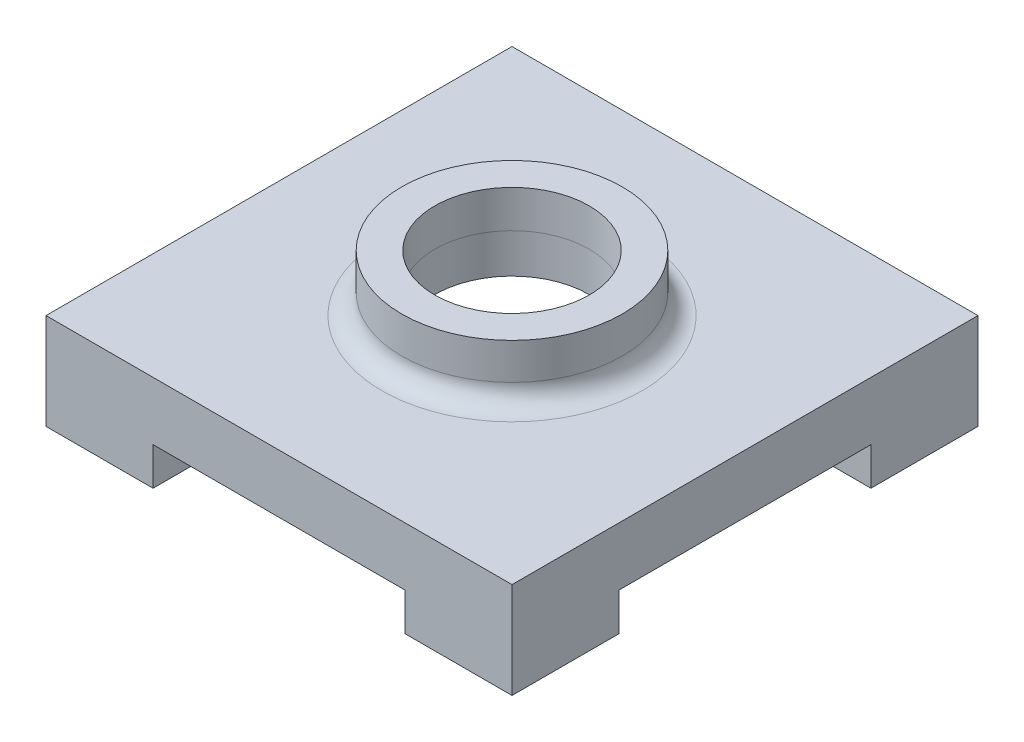
from build123d import *

# Parameters (mm, degrees)
SKETCH1_W            = 18.25
SKETCH1_H            = 40
OUTLINE_DEPTH        = 40
OUTLINE_DEPTH_BACK   = 40
SKETCH2_W            = 40
SKETCH2_H            = 80
EXTRUSION15_DEPTH    = 6
CAMERA_MOUNT_D       = 24.5364
SKETCH5_R            = 17.5
SKETCH5_R_2          = 12.268
EXTRUSION19_DEPTH    = 5.9562
SKETCH10_W           = 80
SKETCH10_H           = 80
SKETCH10_R           = 17.5
CUT_EXTRUDE1_DEPTH   = 3
SKETCH6_W            = 80
SKETCH6_H            = 40
EXTRUSION21_DEPTH    = 6
SKETCH7_W            = 50
SKETCH7_H            = 50
EXTRUSION22_DEPTH    = 9
FILLET4_R            = 3.175
HOLE7_D              = 3.3
HOLE7_DEPTH          = 12
HOLE7_TIP            = 0.991420021
SKETCH11_OUTSIDE_W   = 105.14
SKETCH11_OUTSIDE_H   = 105.14
SKETCH11_OUTSIDE_W_2 = 74
SKETCH11_OUTSIDE_H_2 = 74
CUT_EXTRUDE2_DEPTH   = 16.25
CUT_EXTRUDE3_DEPTH   = 3


with BuildPart() as part:
    # Sketch1 → Outline (new body, two sides)
    with BuildSketch(Plane.YZ) as outline_sk:
        Polygon((18.25, 40), (5.33, 40), (0, 40), (0, 0), (18.25, 0), align=None)
        with Locations((9.125, -20)):
            Rectangle(SKETCH1_W, SKETCH1_H)
    extrude(amount=OUTLINE_DEPTH)
    extrude(outline_sk.sketch, amount=-OUTLINE_DEPTH_BACK)

    # Sketch2 → Extrusion15 (cut)
    with BuildSketch(Plane.XZ):
        Rectangle(SKETCH2_W, SKETCH2_H)
    extrude(amount=-EXTRUSION15_DEPTH, mode=Mode.SUBTRACT)

    # Camera mount (through all)
    with Locations(Plane(origin=(0, 18.25, 0), x_dir=(1, 0, 0), z_dir=(0, 1, 0))):
        with Locations((0, 0)):
            Hole(CAMERA_MOUNT_D / 2)

    # Sketch5 → Extrusion19 (add)
    with BuildSketch(Plane(origin=(0, 18.25, 0), x_dir=(-1, 0, 0), z_dir=(0, 1, 0))):
        Circle(SKETCH5_R)
        Circle(SKETCH5_R_2, mode=Mode.SUBTRACT)
    extrude(amount=EXTRUSION19_DEPTH)

    # Sketch10 → Cut-Extrude1 (cut)
    with BuildSketch(Plane(origin=(0, 18.25, 0), x_dir=(1, 0, 0), z_dir=(0, 1, 0))):
        Rectangle(SKETCH10_W, SKETCH10_H)
        Circle(SKETCH10_R, mode=Mode.SUBTRACT)
    extrude(amount=-CUT_EXTRUDE1_DEPTH, mode=Mode.SUBTRACT)

    # Sketch6 → Extrusion21 (cut)
    with BuildSketch(Plane.XZ):
        Rectangle(SKETCH6_W, SKETCH6_H)
    extrude(amount=-EXTRUSION21_DEPTH, mode=Mode.SUBTRACT)

    # Sketch7 → Extrusion22 (cut)
    with BuildSketch(Plane.XZ):
        Rectangle(SKETCH7_W, SKETCH7_H)
    extrude(amount=-EXTRUSION22_DEPTH, mode=Mode.SUBTRACT)

    # Fillet4
    fillet4_edges = [part.edges().sort_by_distance(p)[0] for p in [
        (-25, 4.5, 25),
        (25, 4.5, -25),
        (25, 4.5, 25),
        (-25, 4.5, -25),
        (-17.5, 15.25, 0),
    ]]
    fillet(fillet4_edges, radius=FILLET4_R)

    # Hole7
    with Locations(Plane(origin=(0, 0, 0), x_dir=(-1, 0, 0), z_dir=(0, -1, 0))):
        with Locations((27.5, 27.5), (-27.5, 27.5), (-27.5, -27.5), (27.5, -27.5)):
            Hole(HOLE7_D / 2, depth=HOLE7_DEPTH)
            with Locations((0, 0, -(HOLE7_DEPTH + HOLE7_TIP / 2))):  # 118° drill point
                Cone(0, HOLE7_D / 2, HOLE7_TIP, mode=Mode.SUBTRACT)

    # Sketch11 outside → Cut-Extrude2 (cut, through all)
    with BuildSketch(Plane(origin=(0, 15.25, 0), x_dir=(1, 0, 0), z_dir=(0, 1, 0))):
        Rectangle(SKETCH11_OUTSIDE_W, SKETCH11_OUTSIDE_H)
        Rectangle(SKETCH11_OUTSIDE_W_2, SKETCH11_OUTSIDE_H_2, mode=Mode.SUBTRACT)
    extrude(amount=-CUT_EXTRUDE2_DEPTH, mode=Mode.SUBTRACT)

    # Sketch13 → Cut-Extrude3 (cut)
    with BuildSketch(Plane.XZ.offset(-9)):
        with BuildLine():
            Line((21.825, 25), (-21.825, 25))
            ThreePointArc((-21.825, 25), (-24.07006403, 24.07006403), (-25, 21.825))
            Line((-25, 21.825), (-25, -21.825))
            ThreePointArc((-25, -21.825), (-24.07006403, -24.07006403), (-21.825, -25))
            Line((-21.825, -25), (21.825, -25))
            ThreePointArc((21.825, -25), (24.07006403, -24.07006403), (25, -21.825))
            Line((25, -21.825), (25, 21.825))
            ThreePointArc((25, 21.825), (24.07006403, 24.07006403), (21.825, 25))
        make_face()
    extrude(amount=-CUT_EXTRUDE3_DEPTH, mode=Mode.SUBTRACT)


solid = part.part
